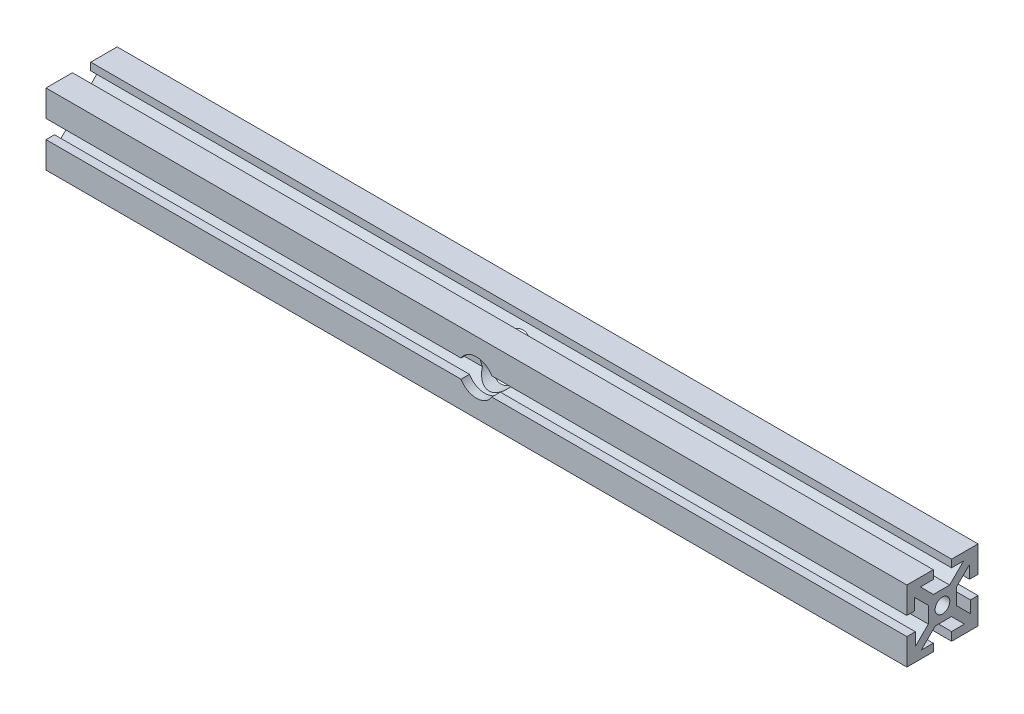
from build123d import *

# Parameters (mm, degrees)
SKETCH1_R               = 2.605
BOSS_EXTRUDE1_DEPTH     = 304.8
CIRPATTERN1_COUNT       = 4
CUT_EXTRUDE1_DEPTH      = 20
CUT_EXTRUDE1_DEPTH_BACK = 30
SKETCH2_R               = 6.35


with BuildPart() as part:
    # Sketch1 → Boss-Extrude1 (new body)
    with BuildSketch(Plane(origin=(0, 0, 0), x_dir=(0, 0, -1), z_dir=(1, 0, 0))):
        Polygon((5, -5), (5, 3.203948776), (9.596194078, 7.800142853), (9.596194078, 3.24), (12.596194078, 3.24), (12.596194078, 12.596194078), (3.24, 12.596194078), (3.24, 9.921463197), (7.474873734, 9.921463197), (2.553410537, 5), (-5, 5), (-5, -5), align=None)
        Circle(SKETCH1_R, mode=Mode.SUBTRACT)
    boss_extrude1 = extrude(amount=BOSS_EXTRUDE1_DEPTH)

    # CirPattern1: Boss-Extrude1 ×4 about axis
    cirpattern1_axis = Axis((0, 0, 0), (1, 0, 0))
    for i in range(1, CIRPATTERN1_COUNT):
        add(boss_extrude1.rotate(cirpattern1_axis, i * 360 / CIRPATTERN1_COUNT))

    # Sketch2 → Cut-Extrude1 (cut, two sides: drawn at the far end of the back side and taken through both)
    with BuildSketch(Plane.XY.offset(-CUT_EXTRUDE1_DEPTH_BACK)):
        with Locations((152.4, 0)):
            Circle(SKETCH2_R)
    extrude(amount=CUT_EXTRUDE1_DEPTH + CUT_EXTRUDE1_DEPTH_BACK, mode=Mode.SUBTRACT)


solid = part.part
